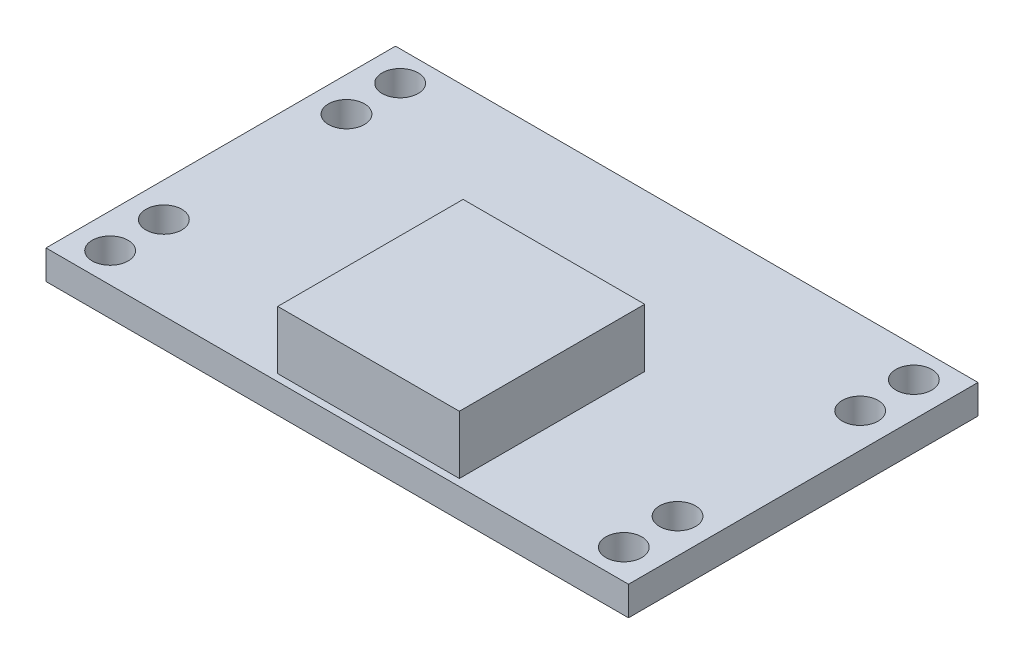
from build123d import *

# Parameters (mm, degrees)
SKETCH1_W               = 30
SKETCH1_H               = 18
BOSS_EXTRUDE1_DEPTH     = 1.5
SKETCH2_W               = 9.352993505
SKETCH2_H               = 9.546694554
BOSS_EXTRUDE2_DEPTH     = 3
SKETCH3_R               = 0.926140641
CUT_EXTRUDE1_DEPTH      = 18.748239349
CIRPATTERN1_COUNT       = 2
MIRROR1_COPY_1_SKETCH_R = 0.926140641
MIRROR1_COPY_1_DEPTH    = 18.748239349


with BuildPart() as part:
    # Sketch1 → Boss-Extrude1 (new body)
    with BuildSketch(Plane(origin=(0, 0, 0), x_dir=(1, 0, 0), z_dir=(0, 1, 0))):
        Rectangle(SKETCH1_W, SKETCH1_H)
    extrude(amount=BOSS_EXTRUDE1_DEPTH)

    # Sketch2 → Boss-Extrude2 (add)
    with BuildSketch(Plane(origin=(0, 1.5, 0), x_dir=(1, 0, 0), z_dir=(0, 1, 0))):
        with Locations((1.252138924, -3.867103084)):
            Rectangle(SKETCH2_W, SKETCH2_H)
    extrude(amount=BOSS_EXTRUDE2_DEPTH)

    # Sketch3 → Cut-Extrude1 (cut, through all)
    with BuildSketch(Plane(origin=(0, 1.5, 0), x_dir=(1, 0, 0), z_dir=(0, 1, 0))):
        with Locations((-13.228024261, 7.468220339)):
            Circle(SKETCH3_R)
        with Locations((-13.228024261, 4.702212806)):
            Circle(SKETCH3_R)
    cut_extrude1 = extrude(amount=-CUT_EXTRUDE1_DEPTH, mode=Mode.SUBTRACT)

    # CirPattern1: Cut-Extrude1 ×2 about axis
    cirpattern1_axis = Axis((0, 0, 0), (0, 1, 0))
    for i in range(1, CIRPATTERN1_COUNT):
        add(cut_extrude1.rotate(cirpattern1_axis, i * 360 / CIRPATTERN1_COUNT), mode=Mode.SUBTRACT)

    # Mirror1: Cut-Extrude1 across plane
    add(cut_extrude1.mirror(Plane(origin=(0, 0, 0), x_dir=(0, 0, 1), z_dir=(1, 0, 0))), mode=Mode.SUBTRACT)

    # Mirror1 copy 1 sketch → Mirror1 copy 1 (cut, through all)
    with BuildSketch(Plane(origin=(0, 1.5, 0), x_dir=(1, 0, 0), z_dir=(0, 1, 0))):
        with Locations((-13.228024261, -7.468220339)):
            Circle(MIRROR1_COPY_1_SKETCH_R)
        with Locations((-13.228024261, -4.702212806)):
            Circle(MIRROR1_COPY_1_SKETCH_R)
    extrude(amount=-MIRROR1_COPY_1_DEPTH, mode=Mode.SUBTRACT)


solid = part.part
